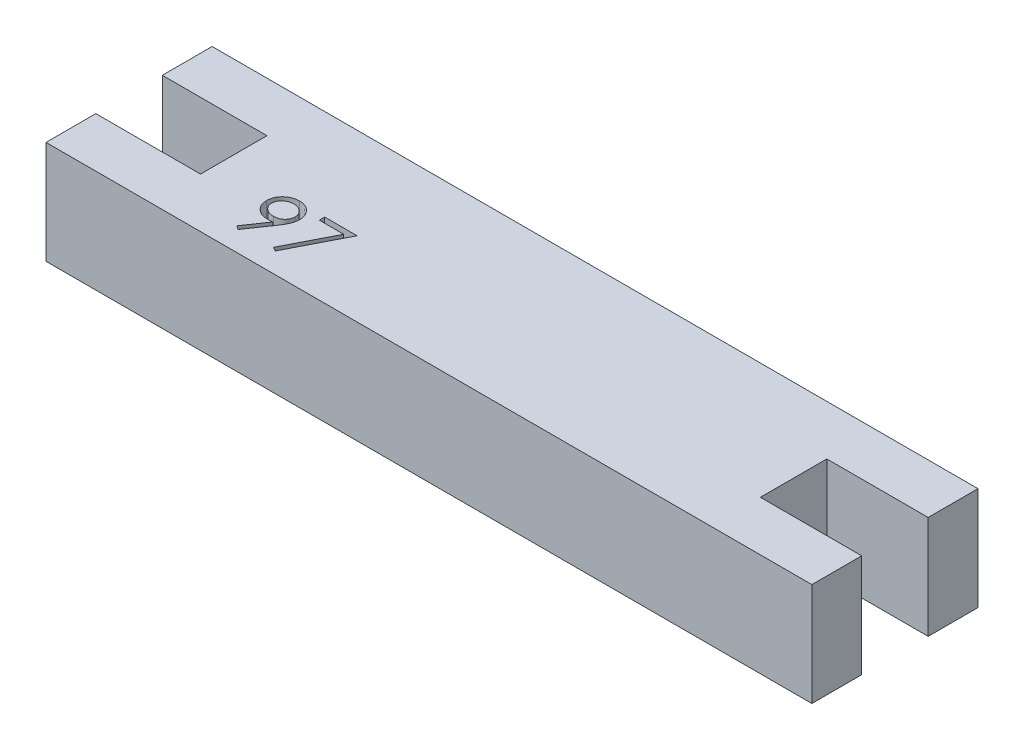
from build123d import *

# Parameters (mm, degrees)
BOSS_EXTRUDE1_DEPTH = 6.2
CUT_EXTRUDE1_DEPTH  = 1


with BuildPart() as part:
    # Sketch1 → Boss-Extrude1 (new body)
    with BuildSketch(Plane(origin=(0, 0, 0), x_dir=(1, 0, 0), z_dir=(0, 1, 0))):
        Polygon((0, 0), (33.7, 0), (39.9, 0), (39.9, 3), (33.8, 3), (33.8, 7), (39.9, 7), (39.9, 10), (33.7, 10), (0, 10), (-6.2, 10), (-6.2, 7), (0.1, 7), (0.1, 3), (-6.2, 3), (-6.2, 0), align=None)
    extrude(amount=BOSS_EXTRUDE1_DEPTH)

    # Sketch2 → Cut-Extrude1 (cut)
    with BuildSketch(Plane(origin=(0, 6.2, 0), x_dir=(1, 0, 0), z_dir=(0, 1, 0))):
        with BuildLine():
            Line((4.122268508, 1.240803577), (3.894574197, 1.399171966))
            Line((3.894574197, 1.399171966), (4.777366665, 2.689651734))
            add(Edge.make_bspline(
                [(4.777366665, 2.689651734), (4.721041498, 2.682763741), (4.610134103, 2.669200898), (4.498431161, 2.66670929), (4.443457411, 2.665483064)],
                knots=[0, 0, 0, 0, 0.000170115, 0.000334967, 0.000334967, 0.000334967, 0.000334967], degree=3))
            add(Edge.make_bspline(
                [(4.443457411, 2.665483064), (4.410127124, 2.666336755), (4.344702687, 2.668012475), (4.248516831, 2.681294687), (4.156092072, 2.701750875), (4.067673442, 2.732275102), (3.982928606, 2.770210192), (3.902042566, 2.817251911), (3.825124208, 2.872593333), (3.752999629, 2.935941833), (3.687402552, 3.00549978), (3.628961417, 3.079119542), (3.580391962, 3.157656315), (3.540045345, 3.239508014), (3.509447005, 3.325851097), (3.487165275, 3.415703053), (3.473447139, 3.509693614), (3.471815102, 3.573669982), (3.470986457, 3.606153136)],
                knots=[0, 0, 0, 0, 9.9954e-05, 0.000196201, 0.000290782, 0.000383503, 0.000476303, 0.000568919, 0.000663705, 0.000760153, 0.000856434, 0.000950205, 0.001041624, 0.001132931, 0.001223461, 0.001315861, 0.001410305, 0.001507717, 0.001507717, 0.001507717, 0.001507717], degree=3))
            add(Edge.make_bspline(
                [(3.470986457, 3.606153136), (3.472559837, 3.6505747), (3.475648063, 3.737765218), (3.500502432, 3.865158708), (3.541378597, 3.985615073), (3.598372911, 4.098817606), (3.670159408, 4.203137891), (3.756436486, 4.2971257), (3.856679368, 4.379444246), (3.968604485, 4.450205088), (4.089574726, 4.507114693), (4.216274151, 4.549060344), (4.34773196, 4.573733494), (4.436784061, 4.576986382), (4.481618468, 4.57862409)],
                knots=[0, 0, 0, 0, 0.000133185, 0.000261414, 0.000387724, 0.00051373, 0.000640399, 0.00076644, 0.000895188, 0.001028407, 0.001162697, 0.001295241, 0.001427846, 0.0015623, 0.0015623, 0.0015623, 0.0015623], degree=3))
            add(Edge.make_bspline(
                [(4.481618468, 4.57862409), (4.525604392, 4.57696387), (4.612516431, 4.573683434), (4.740322887, 4.54965869), (4.862733666, 4.509166851), (4.97907019, 4.45321014), (5.0867838, 4.383069031), (5.183644714, 4.299489856), (5.267442525, 4.202420556), (5.338039902, 4.094208854), (5.394709153, 3.977943093), (5.435596152, 3.856581963), (5.460765411, 3.730998266), (5.463937079, 3.645913279), (5.465537739, 3.602973048)],
                knots=[0, 0, 0, 0, 0.000131915, 0.000260652, 0.000388569, 0.000517718, 0.000646848, 0.000773094, 0.000900237, 0.001030248, 0.001159674, 0.001287189, 0.001413545, 0.001542287, 0.001542287, 0.001542287, 0.001542287], degree=3))
            add(Edge.make_bspline(
                [(5.465537739, 3.602973048), (5.464468754, 3.569641202), (5.462300585, 3.50203589), (5.447118363, 3.399319794), (5.421337195, 3.294589035), (5.392080297, 3.205941588), (5.363838974, 3.132727494), (5.337258661, 3.074895704), (5.307765493, 3.014025272), (5.273367756, 2.950754473), (5.23639053, 2.884276745), (5.194608186, 2.815258852), (5.148973846, 2.74360818), (5.116471172, 2.695305464), (5.099827603, 2.670571205)],
                knots=[0, 0, 0, 0, 9.9984e-05, 0.000202793, 0.000310776, 0.000423207, 0.000482616, 0.000546097, 0.000614079, 0.0006855, 0.000762103, 0.000842274, 0.000927493, 0.001016928, 0.001016928, 0.001016928, 0.001016928], degree=3))
            Line((5.099827603, 2.670571205), (4.122268508, 1.240803577))
        make_face()
        with BuildLine():
            add(Edge.make_bspline(
                [(4.496246874, 2.99112409), (4.521496301, 2.991813867), (4.570648352, 2.993156627), (4.642654901, 3.001329297), (4.710621857, 3.015819984), (4.774730776, 3.036611437), (4.835624466, 3.061699987), (4.892335707, 3.093642288), (4.944911961, 3.131757379), (4.993705294, 3.174583607), (5.037034066, 3.222163779), (5.075626672, 3.271963298), (5.108429472, 3.324200765), (5.134340445, 3.379530367), (5.15564431, 3.436605264), (5.170356364, 3.496344572), (5.178506438, 3.558437049), (5.179895795, 3.600617975), (5.180601842, 3.622053577)],
                knots=[0, 0, 0, 0, 7.5753e-05, 0.000147465, 0.000217073, 0.000283852, 0.000349411, 0.000414338, 0.000478589, 0.000543925, 0.000608743, 0.000671332, 0.000732749, 0.000793345, 0.000854313, 0.000915245, 0.00097749, 0.001041807, 0.001041807, 0.001041807, 0.001041807], degree=3))
            add(Edge.make_bspline(
                [(5.180601842, 3.622053577), (5.179994356, 3.64349813), (5.178797231, 3.685757253), (5.169193038, 3.74794166), (5.1522973, 3.807534833), (5.12962736, 3.864863023), (5.099764001, 3.919455217), (5.063928697, 3.971996815), (5.02135426, 4.022154674), (4.972366218, 4.068749145), (4.919539159, 4.111700453), (4.86324142, 4.149606394), (4.803937031, 4.181375622), (4.741987801, 4.207591116), (4.677264656, 4.228048798), (4.609805896, 4.242760265), (4.539270635, 4.250898928), (4.491390468, 4.252279503), (4.466990063, 4.252983064)],
                knots=[0, 0, 0, 0, 6.4316e-05, 0.000126743, 0.000188161, 0.000249812, 0.000311283, 0.000374438, 0.00044032, 0.000508243, 0.00057698, 0.000644365, 0.000711521, 0.0007785, 0.000845884, 0.000914871, 0.00098532, 0.001058531, 0.001058531, 0.001058531, 0.001058531], degree=3))
            add(Edge.make_bspline(
                [(4.466990063, 4.252983064), (4.442801867, 4.252278367), (4.395344825, 4.250895757), (4.325436623, 4.242775735), (4.258433992, 4.22794986), (4.193898379, 4.207600592), (4.13195099, 4.181373666), (4.072649399, 4.149604729), (4.016338491, 4.111709179), (3.96356208, 4.06871535), (3.914487536, 4.022371556), (3.872645092, 3.971777089), (3.836727776, 3.919482549), (3.806905452, 3.864855759), (3.784224597, 3.807536771), (3.767331781, 3.747941135), (3.757726803, 3.68575739), (3.756529786, 3.643498177), (3.755922355, 3.622053577)],
                knots=[0, 0, 0, 0, 7.2576e-05, 0.000142393, 0.000210758, 0.000278143, 0.000345121, 0.000412278, 0.000479663, 0.0005484, 0.000616323, 0.000681795, 0.00074495, 0.000806421, 0.000868072, 0.00092949, 0.000991917, 0.001056233, 0.001056233, 0.001056233, 0.001056233], degree=3))
            add(Edge.make_bspline(
                [(3.755922355, 3.622053577), (3.756472016, 3.600601282), (3.757556049, 3.558293431), (3.768013401, 3.496130203), (3.785501555, 3.436541627), (3.808923431, 3.3789483), (3.839767731, 3.323910258), (3.877617221, 3.271688436), (3.921981538, 3.221690849), (3.97226763, 3.174694307), (4.027302319, 3.131557691), (4.086082225, 3.093883702), (4.147595434, 3.062067984), (4.212058485, 3.036539729), (4.278993653, 3.01602772), (4.349002522, 3.001356004), (4.421853566, 2.993235019), (4.471211193, 2.991834484), (4.496246874, 2.99112409)],
                knots=[0, 0, 0, 0, 6.4316e-05, 0.000126844, 0.000188436, 0.000250326, 0.000312966, 0.000377217, 0.000443451, 0.000513196, 0.000583426, 0.000652939, 0.000722346, 0.000790847, 0.000860662, 0.000932137, 0.001005113, 0.00108023, 0.00108023, 0.00108023, 0.00108023], degree=3))
        make_face(mode=Mode.SUBTRACT)
        Polygon((6.076114662, 4.497213833), (8.029960816, 4.497213833), (6.36105056, 1.240803577), (6.114911738, 1.376275332), (7.547859454, 4.171572808), (6.076114662, 4.171572808), align=None)
    extrude(amount=-CUT_EXTRUDE1_DEPTH, mode=Mode.SUBTRACT)


solid = part.part
